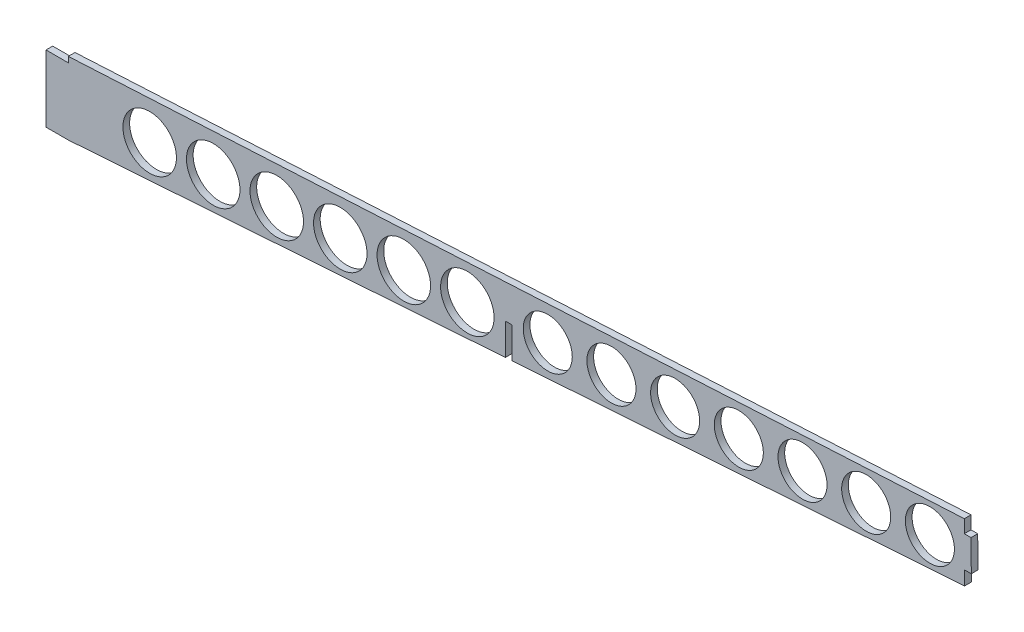
from build123d import *

# Parameters (mm, degrees)
BOSS_EXTRUDE1_DEPTH     = 3
SKETCH2_R               = 12
SKETCH2_R_2             = 11
SKETCH2_W               = 3
SKETCH2_H               = 14.132174157
CUT_EXTRUDE1_DEPTH      = 1
CUT_EXTRUDE1_DEPTH_BACK = 4
CUT_EXTRUDE2_DEPTH      = 10


with BuildPart() as part:
    # Sketch1 → Boss-Extrude1 (new body)
    with BuildSketch(Plane.XY):
        Polygon((-415, 0), (-415, 30), (-405, 30), (-405, 32.5), (-0.255808808, 54.019626957), (0, 28.020885413), (-405, 0), align=None)
    extrude(amount=BOSS_EXTRUDE1_DEPTH)

    # Sketch2 → Cut-Extrude1 (cut, two sides)
    with BuildSketch(Plane.XY.offset(3)) as cut_extrude1_sk:
        with Locations((-368.509952953, 17.345136607)):
            Circle(SKETCH2_R)
        with Locations((-340.019905905, 19.176130471)):
            Circle(SKETCH2_R)
        with Locations((-311.529858858, 21.007124335)):
            Circle(SKETCH2_R)
        with Locations((-283.039811811, 22.8381182)):
            Circle(SKETCH2_R)
        with Locations((-254.549764764, 24.669112064)):
            Circle(SKETCH2_R)
        with Locations((-190, 28.817586197)):
            Circle(SKETCH2_R_2)
        with Locations((-161.439118955, 30.65313241)):
            Circle(SKETCH2_R_2)
        with Locations((-132.878237911, 32.488678622)):
            Circle(SKETCH2_R_2)
        with Locations((-104.317356866, 34.324224835)):
            Circle(SKETCH2_R_2)
        with Locations((-75.756475821, 36.159771047)):
            Circle(SKETCH2_R_2)
        with Locations((-47.195594776, 37.99531726)):
            Circle(SKETCH2_R_2)
        with Locations((-18.634713732, 39.830863473)):
            Circle(SKETCH2_R_2)
        with Locations((-226.059717716, 26.500105928)):
            Circle(SKETCH2_R)
        with Locations((-207.5, 20.626811871)):
            Rectangle(SKETCH2_W, SKETCH2_H)
    extrude(amount=CUT_EXTRUDE1_DEPTH, mode=Mode.SUBTRACT)
    extrude(cut_extrude1_sk.sketch, amount=-CUT_EXTRUDE1_DEPTH_BACK, mode=Mode.SUBTRACT)

    # Sketch3 → Cut-Extrude2 (cut)
    with BuildSketch(Plane.XY.offset(3)):
        Polygon((-0.255808808, 54.019626957), (-3.196773149, 53.8632604), (-3.196773149, 48.019626957), (-0.196773149, 48.019626957), align=None)
        Polygon((0, 28.020885413), (-3.059035659, 27.809238777), (-3.059035659, 34.020885413), (-0.059035659, 34.020885413), align=None)
    extrude(amount=-CUT_EXTRUDE2_DEPTH, mode=Mode.SUBTRACT)


solid = part.part
